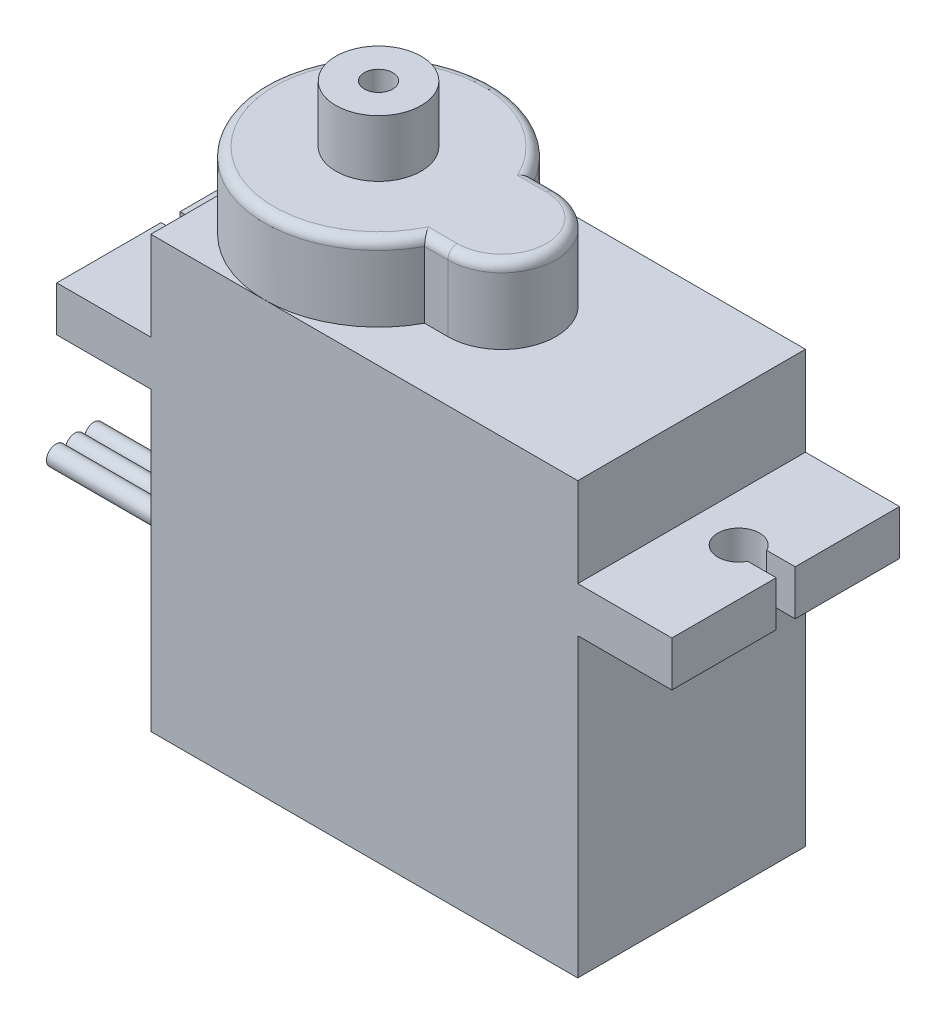
from build123d import *

# Parameters (mm, degrees)
BODY_DEPTH             = 4.7
BODY_DEPTH_BACK        = 18
ESBO_O1_W              = 22.5
ESBO_O1_H              = 12
TABS_DEPTH             = 2.375
TOP_GEAR_HOUSING_DEPTH = 4
ESBO_O4_R              = 2.25
SHAFT_DEPTH            = 3
ESBO_O5_R              = 0.75
SHAFT_HOLE_DEPTH       = 5
FILETE2_R              = 0.5
SKETCH1_R              = 0.5
BOSS_EXTRUDE1_DEPTH    = 10
LPATTERN2_COUNT        = 3
LPATTERN2_PITCH        = 1.001


with BuildPart() as part:
    # Esboço1 → Body (new, two sides: drawn at the far end of the back side and taken through both)
    with BuildSketch(Plane(origin=(0, 0, 0), x_dir=(1, 0, 0), z_dir=(0, 1, 0)).offset(-BODY_DEPTH_BACK)):
        Rectangle(ESBO_O1_W, ESBO_O1_H)
    extrude(amount=BODY_DEPTH + BODY_DEPTH_BACK)

    # Esboço2 → tabs (add)
    with BuildSketch(Plane(origin=(0, 0, 0), x_dir=(1, 0, 0), z_dir=(0, 1, 0))):
        with BuildLine():
            Line((-11.25, 6), (-16.21, 6))
            Line((-16.21, 6), (-16.21, 0.5))
            Line((-16.21, 0.5), (-14.954795897, 0.5))
            ThreePointArc((-14.954795897, 0.5), (-12.875, 0), (-14.954795897, -0.5))
            Line((-14.954795897, -0.5), (-16.21, -0.5))
            Line((-16.21, -0.5), (-16.21, -6))
            Line((-16.21, -6), (-11.25, -6))
            Line((-11.25, -6), (-11.25, 6))
        make_face()
        with BuildLine():
            Line((11.25, 6), (16.21, 6))
            Line((16.21, 6), (16.21, 0.5))
            Line((16.21, 0.5), (14.709795897, 0.5))
            ThreePointArc((14.709795897, 0.5), (12.63, 0), (14.709795897, -0.5))
            Line((14.709795897, -0.5), (16.21, -0.5))
            Line((16.21, -0.5), (16.21, -6))
            Line((16.21, -6), (11.25, -6))
            Line((11.25, -6), (11.25, 6))
        make_face()
    extrude(amount=-TABS_DEPTH)

    # Esboço3 → Top Gear Housing (add)
    with BuildSketch(Plane(origin=(0, 4.7, 0), x_dir=(1, 0, 0), z_dir=(0, 1, 0))):
        with BuildLine():
            Line((0.029914772, 2.85), (1.25, 2.85))
            ThreePointArc((1.25, 2.85), (4.1, 0), (1.25, -2.85))
            Line((1.25, -2.85), (0.029914772, -2.85))
            ThreePointArc((0.029914772, -2.85), (-11.25, 0), (0.029914772, 2.85))
        make_face()
    extrude(amount=TOP_GEAR_HOUSING_DEPTH)

    # Esboço4 → shaft (add)
    with BuildSketch(Plane(origin=(0, 8.7, 0), x_dir=(1, 0, 0), z_dir=(0, 1, 0))):
        with Locations((-5.25, 0)):
            Circle(ESBO_O4_R)
    extrude(amount=SHAFT_DEPTH)

    # Esboço5 → shaft hole (cut)
    with BuildSketch(Plane(origin=(0, 11.7, 0), x_dir=(1, 0, 0), z_dir=(0, 1, 0))):
        with Locations((-5.25, 0)):
            Circle(ESBO_O5_R)
    extrude(amount=-SHAFT_HOLE_DEPTH, mode=Mode.SUBTRACT)

    # Filete2
    filete2_edges = [part.edges().sort_by_distance(p)[0] for p in [
        (0.639957386, 8.7, 2.85),
        (0.639957386, 8.7, -2.85),
        (4.1, 8.7, 0),
        (-11.25, 8.7, 0),
    ]]
    fillet(filete2_edges, radius=FILETE2_R)

    # Sketch1 → Boss-Extrude1 (add)
    with BuildSketch(Plane.ZY.offset(11.25)):
        with Locations((-1, -12.875)):
            Circle(SKETCH1_R)
    boss_extrude1 = extrude(amount=BOSS_EXTRUDE1_DEPTH)

    # LPattern2: Boss-Extrude1 ×3
    with Locations(*[(0, 0, i * LPATTERN2_PITCH) for i in range(1, LPATTERN2_COUNT)]):
        add(boss_extrude1)


solid = part.part
